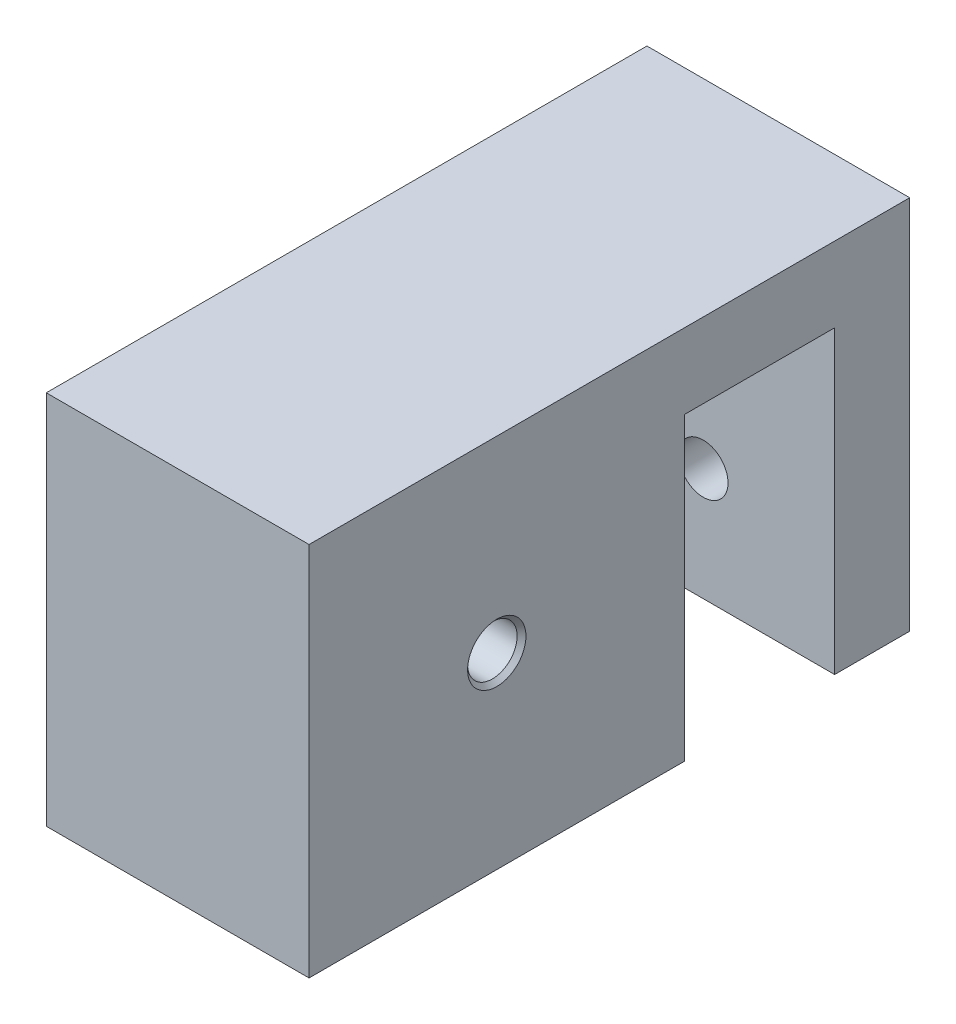
from build123d import *

# Parameters (mm, degrees)
SKETCH_2_W                      = 50
SKETCH_2_H                      = 50
EXTRUDE_1_DEPTH                 = 35
SKETCH_3_R                      = 20
CUT_EXTRUDE_1_DEPTH             = 20
HOLE_WIZARD_G1_16_1_D           = 6.6
HOLE_WIZARD_G1_16_1_DEPTH       = 20
HOLE_WIZARD_G1_16_1_CSINK_D     = 7.773
HOLE_WIZARD_G1_16_1_CSINK_ANGLE = 90
HOLE_WIZARD_G1_16_1_TIP         = 1.982840043
SKETCH_6_W                      = 35
SKETCH_6_H                      = 10
EXTRUDE_2_DEPTH                 = 30
SKETCH_7_W                      = 35
SKETCH_7_H                      = 10
EXTRUDE_3_DEPTH                 = 40
HOLE_WIZARD_G1_16_2_D           = 6.6
HOLE_WIZARD_G1_16_2_DEPTH       = 20
HOLE_WIZARD_G1_16_2_CSINK_D     = 7.773
HOLE_WIZARD_G1_16_2_CSINK_ANGLE = 90
HOLE_WIZARD_G1_16_2_TIP         = 1.982840043


with BuildPart() as part:
    # 草图2 → 凸台-拉伸1 (new body)
    with BuildSketch(Plane(origin=(0, 0, 0), x_dir=(0, 0, -1), z_dir=(1, 0, 0))):
        with Locations((25, -25)):
            Rectangle(SKETCH_2_W, SKETCH_2_H)
    extrude(amount=EXTRUDE_1_DEPTH)

    # 草图3 → 切除-拉伸1 (cut)
    with BuildSketch(Plane.ZY):
        with Locations((-25, -25)):
            Circle(SKETCH_3_R)
    extrude(amount=-CUT_EXTRUDE_1_DEPTH, mode=Mode.SUBTRACT)

    # G1/16 螺纹孔1
    with Locations(Plane(origin=(35, 0, 0), x_dir=(0, 0, -1), z_dir=(1, 0, 0))):
        with Locations((25, -25)):
            CounterSinkHole(HOLE_WIZARD_G1_16_1_D / 2, HOLE_WIZARD_G1_16_1_CSINK_D / 2, depth=HOLE_WIZARD_G1_16_1_DEPTH, counter_sink_angle=HOLE_WIZARD_G1_16_1_CSINK_ANGLE)
            with Locations((0, 0, -(HOLE_WIZARD_G1_16_1_DEPTH + HOLE_WIZARD_G1_16_1_TIP / 2))):  # 118° drill point
                Cone(0, HOLE_WIZARD_G1_16_1_D / 2, HOLE_WIZARD_G1_16_1_TIP, mode=Mode.SUBTRACT)

    # 草图6 → 凸台-拉伸2 (add)
    with BuildSketch(Plane(origin=(0, 0, -50), x_dir=(-1, 0, 0), z_dir=(0, 0, -1))):
        with Locations((-17.5, -5)):
            Rectangle(SKETCH_6_W, SKETCH_6_H)
    extrude(amount=EXTRUDE_2_DEPTH)

    # 草图7 → 凸台-拉伸3 (add)
    with BuildSketch(Plane(origin=(0, -10, 0), x_dir=(-1, 0, 0), z_dir=(0, -1, 0))):
        with Locations((-17.5, 75)):
            Rectangle(SKETCH_7_W, SKETCH_7_H)
    extrude(amount=EXTRUDE_3_DEPTH)

    # G1/16 螺纹孔2
    with Locations(Plane(origin=(0, 0, -80), x_dir=(-1, 0, 0), z_dir=(0, 0, -1))):
        with Locations((-17.5, -35)):
            CounterSinkHole(HOLE_WIZARD_G1_16_2_D / 2, HOLE_WIZARD_G1_16_2_CSINK_D / 2, depth=HOLE_WIZARD_G1_16_2_DEPTH, counter_sink_angle=HOLE_WIZARD_G1_16_2_CSINK_ANGLE)
            with Locations((0, 0, -(HOLE_WIZARD_G1_16_2_DEPTH + HOLE_WIZARD_G1_16_2_TIP / 2))):  # 118° drill point
                Cone(0, HOLE_WIZARD_G1_16_2_D / 2, HOLE_WIZARD_G1_16_2_TIP, mode=Mode.SUBTRACT)


solid = part.part
